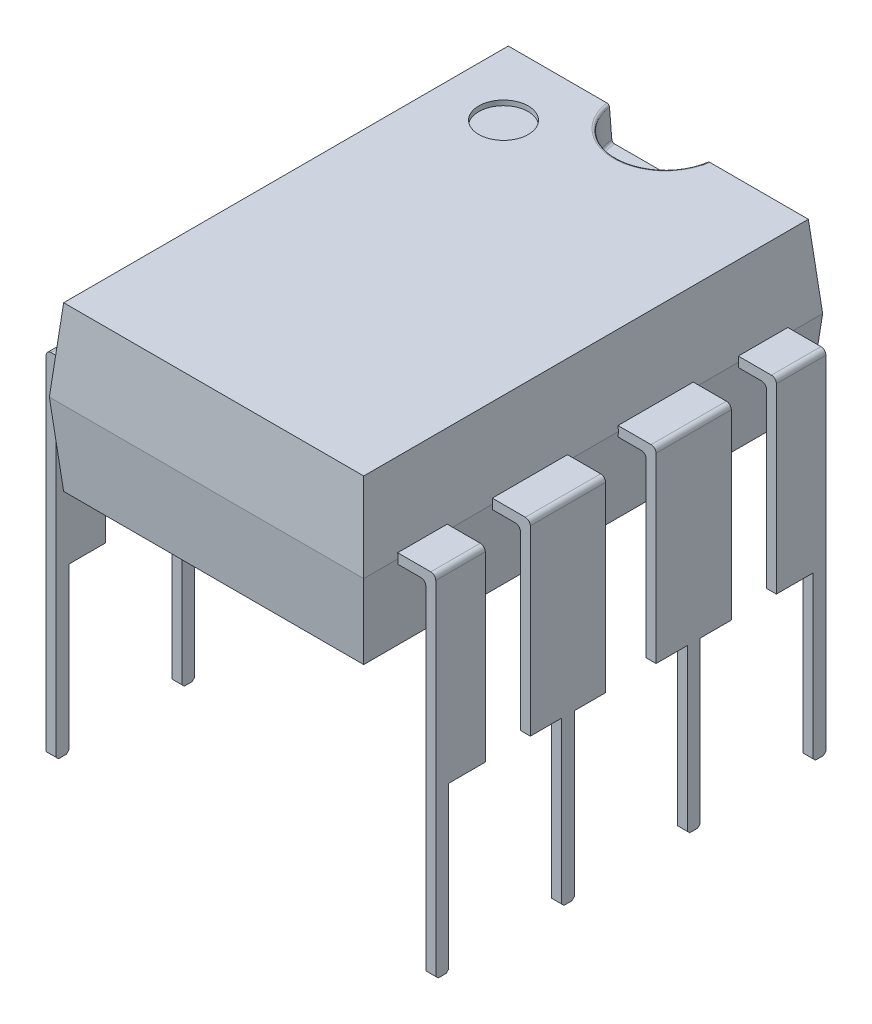
from build123d import *

# Parameters (mm, degrees)
Y_KSEKLIK_EKSTR_ZYON1_DEPTH      = 3.175
Y_KSEKLIK_EKSTR_ZYON1_DEPTH_BACK = 3.175
KES_EKSTR_ZYON1_DEPTH            = 5.635
KES_EKSTR_ZYON1_DEPTH_BACK       = 5.635
Y_KSEKLIK_EKSTR_ZYON2_DEPTH      = 1
IZIM4_W                          = 0.2
IZIM4_H                          = 3.3
Y_KSEKLIK_EKSTR_ZYON3_DEPTH      = 0.26
Y_KSEKLIK_EKSTR_ZYON4_DEPTH      = 0.76
IZIM6_W                          = 0.2
IZIM6_H                          = 3.3
Y_KSEKLIK_EKSTR_ZYON5_DEPTH      = 0.13
L_O_ALTMA1_COUNT                 = 2
L_O_ALTMA1_PITCH                 = 2.54
AYNALAMA3_COPY_1_DEPTH           = 1
AYNALAMA3_COPY_2_SKETCH_W        = 0.2
AYNALAMA3_COPY_2_SKETCH_H        = 3.3
AYNALAMA3_COPY_2_DEPTH           = 0.26
AYNALAMA3_COPY_3_DEPTH           = 0.76
AYNALAMA3_COPY_4_SKETCH_W        = 0.2
AYNALAMA3_COPY_4_SKETCH_H        = 3.3
AYNALAMA3_COPY_4_DEPTH           = 0.13
KES_EKSTR_ZYON3_DEPTH            = 0.7
RADYUS1_R                        = 0.05
IZIM8_R                          = 0.5
KES_EKSTR_ZYON4_DEPTH            = 0.1
PAH2_SIZE                        = 0.05


with BuildPart() as part:
    # izim1 → Y_kseklik-Ekstr_zyon1 (new body, two sides)
    with BuildSketch(Plane(origin=(0, 0, 0), x_dir=(0, 0, -1), z_dir=(1, 0, 0))) as y_kseklik_ekstr_zyon1_sk:
        Polygon((-4.635, 0), (-4.490643705, 1.65), (4.490643705, 1.65), (4.635, 0), (4.490643705, -1.65), (-4.490643705, -1.65), align=None)
    extrude(amount=Y_KSEKLIK_EKSTR_ZYON1_DEPTH)
    extrude(y_kseklik_ekstr_zyon1_sk.sketch, amount=-Y_KSEKLIK_EKSTR_ZYON1_DEPTH_BACK)

    # izim2 → Kes-Ekstr_zyon1 (cut, two sides)
    with BuildSketch(Plane.XY) as kes_ekstr_zyon1_sk:
        Polygon((-3.175, 1.65), (-3.175, 0), (-3.030643705, 1.65), align=None)
        Polygon((-3.030643705, -1.65), (-3.175, 0), (-3.175, -1.65), align=None)
        Polygon((3.175, 0), (3.175, 1.65), (3.030643705, 1.65), align=None)
        Polygon((3.175, -1.65), (3.175, 0), (3.030643705, -1.65), align=None)
    extrude(amount=KES_EKSTR_ZYON1_DEPTH, mode=Mode.SUBTRACT)
    extrude(kes_ekstr_zyon1_sk.sketch, amount=-KES_EKSTR_ZYON1_DEPTH_BACK, mode=Mode.SUBTRACT)

    # izim3 → Y_kseklik-Ekstr_zyon2 (add)
    with BuildSketch(Plane.XY.offset(3.94)):
        with BuildLine():
            Line((-3.175, 0.1), (-3.835, 0.1))
            ThreePointArc((-3.835, 0.1), (-3.905710678, 0.070710678), (-3.935, 0))
            Line((-3.935, 0), (-3.935, -3.68))
            Line((-3.935, -3.68), (-3.735, -3.68))
            Line((-3.735, -3.68), (-3.735, -0.2))
            ThreePointArc((-3.735, -0.2), (-3.705710678, -0.129289322), (-3.635, -0.1))
            Line((-3.635, -0.1), (-3.175, -0.1))
            Line((-3.175, -0.1), (-3.166251134, -0.1))
            Line((-3.166251134, -0.1), (-3.175, 0))
            Line((-3.175, 0), (-3.166251134, 0.1))
            Line((-3.166251134, 0.1), (-3.175, 0.1))
        make_face()
    y_kseklik_ekstr_zyon2 = extrude(amount=-Y_KSEKLIK_EKSTR_ZYON2_DEPTH)

    # izim4 → Y_kseklik-Ekstr_zyon3 (add)
    with BuildSketch(Plane.XY.offset(3.94)):
        with Locations((-3.835, -5.33)):
            Rectangle(IZIM4_W, IZIM4_H)
    y_kseklik_ekstr_zyon3 = extrude(amount=-Y_KSEKLIK_EKSTR_ZYON3_DEPTH)

    # izim5 → Y_kseklik-Ekstr_zyon4 (add, symmetric)
    with BuildSketch(Plane(origin=(0, 0, 1.27), x_dir=(-1, 0, 0), z_dir=(0, 0, -1))):
        with BuildLine():
            Line((3.935, -3.68), (3.735, -3.68))
            Line((3.735, -3.68), (3.735, -0.2))
            ThreePointArc((3.735, -0.2), (3.705710678, -0.129289322), (3.635, -0.1))
            Line((3.635, -0.1), (3.166251134, -0.1))
            Line((3.166251134, -0.1), (3.175, 0))
            Line((3.175, 0), (3.166251134, 0.1))
            Line((3.166251134, 0.1), (3.835, 0.1))
            ThreePointArc((3.835, 0.1), (3.905710678, 0.070710678), (3.935, 0))
            Line((3.935, 0), (3.935, -3.68))
        make_face()
    y_kseklik_ekstr_zyon4 = extrude(amount=Y_KSEKLIK_EKSTR_ZYON4_DEPTH, both=True)

    # izim6 → Y_kseklik-Ekstr_zyon5 (add, symmetric)
    with BuildSketch(Plane(origin=(0, 0, 1.27), x_dir=(-1, 0, 0), z_dir=(0, 0, -1))):
        with Locations((3.835, -5.33)):
            Rectangle(IZIM6_W, IZIM6_H)
    y_kseklik_ekstr_zyon5 = extrude(amount=Y_KSEKLIK_EKSTR_ZYON5_DEPTH, both=True)

    # L_o_altma1: Y_kseklik-Ekstr_zyon4, Y_kseklik-Ekstr_zyon5 ×2
    with Locations(*[(0, 0, -i * L_O_ALTMA1_PITCH) for i in range(1, L_O_ALTMA1_COUNT)]):
        add(y_kseklik_ekstr_zyon4)
        add(y_kseklik_ekstr_zyon5)

    # Aynalama2: Y_kseklik-Ekstr_zyon2, Y_kseklik-Ekstr_zyon3 across plane
    add(y_kseklik_ekstr_zyon2.mirror(Plane.XY))
    add(y_kseklik_ekstr_zyon3.mirror(Plane.XY))

    # Aynalama3: Y_kseklik-Ekstr_zyon4, Y_kseklik-Ekstr_zyon2, Y_kseklik-Ekstr_zyon3, Y_kseklik-Ekstr_zyon5 across plane
    add(y_kseklik_ekstr_zyon4.mirror(Plane(origin=(0, 0, 0), x_dir=(0, 0, 1), z_dir=(1, 0, 0))))
    add(y_kseklik_ekstr_zyon2.mirror(Plane(origin=(0, 0, 0), x_dir=(0, 0, 1), z_dir=(1, 0, 0))))
    add(y_kseklik_ekstr_zyon3.mirror(Plane(origin=(0, 0, 0), x_dir=(0, 0, 1), z_dir=(1, 0, 0))))
    add(y_kseklik_ekstr_zyon5.mirror(Plane(origin=(0, 0, 0), x_dir=(0, 0, 1), z_dir=(1, 0, 0))))

    # Aynalama3 copy 1 sketch → Aynalama3 copy 1 (add)
    with BuildSketch(Plane(origin=(0, 0, -3.94), x_dir=(-1, 0, 0), z_dir=(0, 0, -1))):
        with BuildLine():
            Line((-3.175, 0.1), (-3.835, 0.1))
            ThreePointArc((-3.835, 0.1), (-3.905710678, 0.070710678), (-3.935, 0))
            Line((-3.935, 0), (-3.935, -3.68))
            Line((-3.935, -3.68), (-3.735, -3.68))
            Line((-3.735, -3.68), (-3.735, -0.2))
            ThreePointArc((-3.735, -0.2), (-3.705710678, -0.129289322), (-3.635, -0.1))
            Line((-3.635, -0.1), (-3.175, -0.1))
            Line((-3.175, -0.1), (-3.166251134, -0.1))
            Line((-3.166251134, -0.1), (-3.175, 0))
            Line((-3.175, 0), (-3.166251134, 0.1))
            Line((-3.166251134, 0.1), (-3.175, 0.1))
        make_face()
    extrude(amount=-AYNALAMA3_COPY_1_DEPTH)

    # Aynalama3 copy 2 sketch → Aynalama3 copy 2 (add)
    with BuildSketch(Plane(origin=(0, 0, -3.94), x_dir=(-1, 0, 0), z_dir=(0, 0, -1))):
        with Locations((-3.835, -5.33)):
            Rectangle(AYNALAMA3_COPY_2_SKETCH_W, AYNALAMA3_COPY_2_SKETCH_H)
    extrude(amount=-AYNALAMA3_COPY_2_DEPTH)

    # Aynalama3 copy 3 sketch → Aynalama3 copy 3 (add, symmetric)
    with BuildSketch(Plane(origin=(0, 0, -1.27), x_dir=(1, 0, 0), z_dir=(0, 0, -1))):
        with BuildLine():
            Line((3.935, 3.68), (3.735, 3.68))
            Line((3.735, 3.68), (3.735, 0.2))
            ThreePointArc((3.735, 0.2), (3.705710678, 0.129289322), (3.635, 0.1))
            Line((3.635, 0.1), (3.166251134, 0.1))
            Line((3.166251134, 0.1), (3.175, 0))
            Line((3.175, 0), (3.166251134, -0.1))
            Line((3.166251134, -0.1), (3.835, -0.1))
            ThreePointArc((3.835, -0.1), (3.905710678, -0.070710678), (3.935, 0))
            Line((3.935, 0), (3.935, 3.68))
        make_face()
    extrude(amount=AYNALAMA3_COPY_3_DEPTH, both=True)

    # Aynalama3 copy 4 sketch → Aynalama3 copy 4 (add, symmetric)
    with BuildSketch(Plane(origin=(0, 0, -1.27), x_dir=(1, 0, 0), z_dir=(0, 0, -1))):
        with Locations((3.835, 5.33)):
            Rectangle(AYNALAMA3_COPY_4_SKETCH_W, AYNALAMA3_COPY_4_SKETCH_H)
    extrude(amount=AYNALAMA3_COPY_4_DEPTH, both=True)

    # izim7 → Kes-Ekstr_zyon3 (cut)
    with BuildSketch(Plane(origin=(0, 1.65, 0), x_dir=(1, 0, 0), z_dir=(0, 1, 0))):
        with BuildLine():
            Line((-1, 4.635), (1, 4.635))
            ThreePointArc((1, 4.635), (0, 3.635), (-1, 4.635))
        make_face()
    extrude(amount=-KES_EKSTR_ZYON3_DEPTH, mode=Mode.SUBTRACT)

    # Radyus1
    radyus1_edges = [part.edges().sort_by_distance(p)[0] for p in [
        (0, 0.95, -3.635),
        (0, 1.65, -3.635),
    ]]
    fillet(radyus1_edges, radius=RADYUS1_R)

    # izim8 → Kes-Ekstr_zyon4 (cut)
    with BuildSketch(Plane(origin=(0, 1.65, 0), x_dir=(1, 0, 0), z_dir=(0, 1, 0))):
        with Locations((-1.780643705, 3.144473012)):
            Circle(IZIM8_R)
    extrude(amount=-KES_EKSTR_ZYON4_DEPTH, mode=Mode.SUBTRACT)

    # Pah2
    pah2_edges = [part.edges().sort_by_distance(p)[0] for p in [
        (-3.835, -6.98, 3.68),
        (-3.835, -6.98, 3.94),
        (-3.835, -6.98, 1.4),
        (-3.835, -6.98, 1.14),
        (-3.835, -6.98, -1.14),
        (-3.835, -6.98, -1.4),
        (-3.835, -6.98, -3.94),
        (-3.835, -6.98, -3.68),
        (3.835, -6.98, 1.14),
        (3.835, -6.98, 1.4),
        (3.835, -6.98, -1.4),
        (3.835, -6.98, -1.14),
        (3.835, -6.98, -3.68),
        (3.835, -6.98, -3.94),
        (3.835, -6.98, 3.94),
        (3.835, -6.98, 3.68),
    ]]
    chamfer(pah2_edges, length=PAH2_SIZE)


solid = part.part
